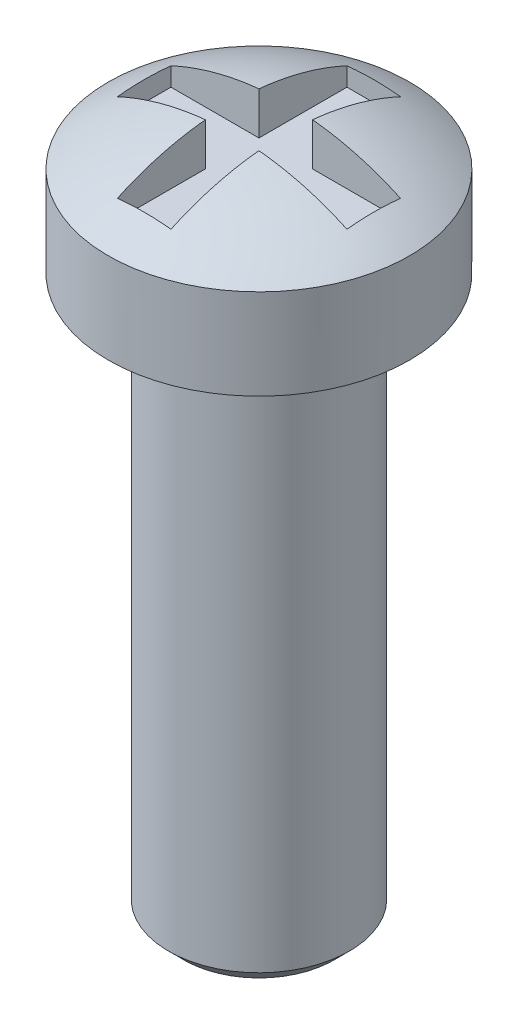
from build123d import *

# Parameters (mm, degrees)
SKETCH2_W      = 0.889
SKETCH2_H      = 1.64826619
EXTRUDE1_DEPTH = 1.905
SKETCH3_W      = 0.889
SKETCH3_H      = 2.39619966
EXTRUDE2_DEPTH = 1.905
CHAMFER1_SIZE  = 0.254


with BuildPart() as part:
    # Sketch1 → Revolve1 (revolve)
    with BuildSketch(Plane.XY):
        with BuildLine():
            Line((0, 0), (0, -11.5))
            Line((0, -11.5), (1.5, -11.5))
            Line((1.5, -11.5), (1.5, -2.25))
            Line((1.5, -2.25), (2.5, -2.25))
            Line((2.5, -2.25), (2.5, -0.75))
            ThreePointArc((2.5, -0.75), (1.305038314, -0.191538955), (0, 0))
        make_face()
    revolve(axis=Axis((0, 0, 0), (0, -1, 0)))

    # Sketch2 → Extrude1 (cut, symmetric)
    with BuildSketch(Plane.XY):
        with Locations((0, 0.074133095)):
            Rectangle(SKETCH2_W, SKETCH2_H)
    extrude(amount=EXTRUDE1_DEPTH, both=True, mode=Mode.SUBTRACT)

    # Sketch3 → Extrude2 (cut, symmetric)
    with BuildSketch(Plane(origin=(0, 0, 0), x_dir=(0, 0, -1), z_dir=(1, 0, 0))):
        with Locations((0, 0.44809983)):
            Rectangle(SKETCH3_W, SKETCH3_H)
    extrude(amount=EXTRUDE2_DEPTH, both=True, mode=Mode.SUBTRACT)

    # Chamfer1
    chamfer1_edges = [part.edges().sort_by_distance(p)[0] for p in [
        (-1.5, -11.5, 0),
    ]]
    chamfer(chamfer1_edges, length=CHAMFER1_SIZE)


solid = part.part
